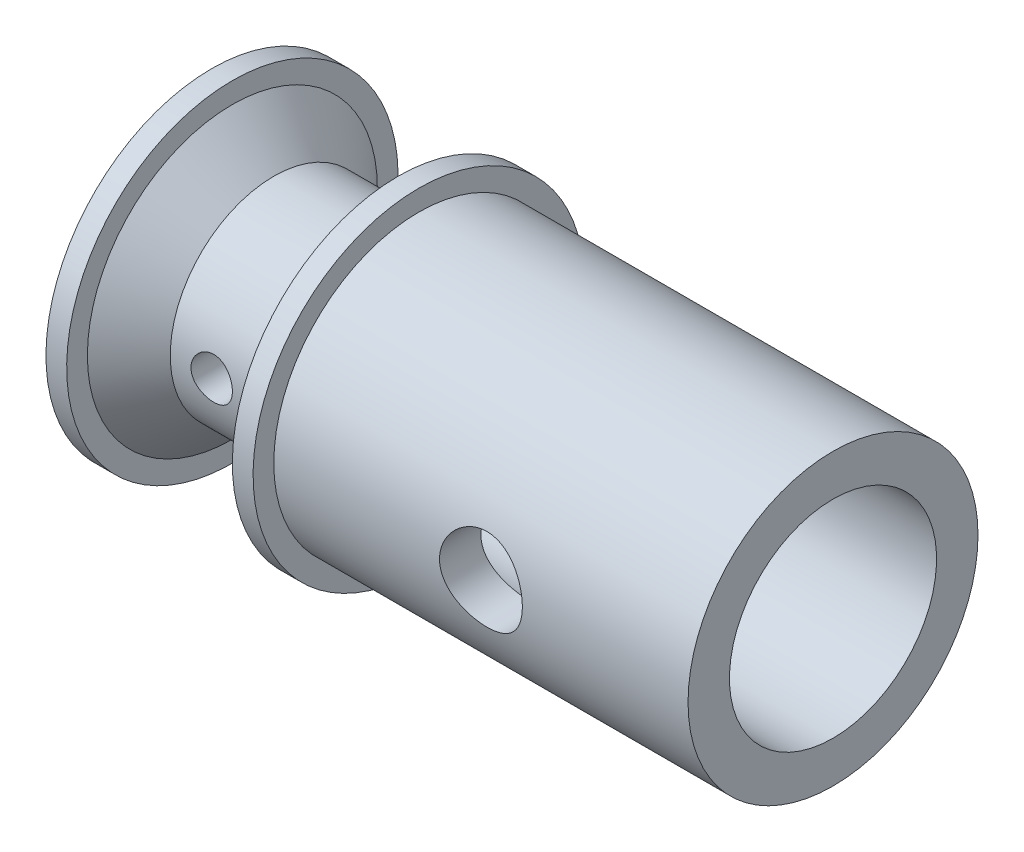
from build123d import *

# Parameters (mm, degrees)
SKETCH3_R               = 0.5
SKETCH3_R_2             = 1
CUT_EXTRUDE1_DEPTH      = 5
CUT_EXTRUDE1_DEPTH_BACK = 5


with BuildPart() as part:
    # Sketch1 → Revolve1 (revolve)
    with BuildSketch(Plane.XY):
        Polygon((0, 0), (0, 2.5), (10, 2.5), (10, 3.5), (0, 3.5), (0, 4), (-0.5, 4), (-0.5, 3.5), (-1.5, 2.5), (-3.5, 2.5), (-4.5, 3.5), (-4.5, 4), (-5, 4), (-5, 0), align=None)
    revolve(axis=Axis((0, 0, 0), (-1, 0, 0)))

    # Sketch3 → Cut-Extrude1 (cut, two sides)
    with BuildSketch(Plane.XY) as cut_extrude1_sk:
        with Locations((-2.5, 0)):
            Circle(SKETCH3_R)
        with Locations((5, 0)):
            Circle(SKETCH3_R_2)
    extrude(amount=CUT_EXTRUDE1_DEPTH, mode=Mode.SUBTRACT)
    extrude(cut_extrude1_sk.sketch, amount=-CUT_EXTRUDE1_DEPTH_BACK, mode=Mode.SUBTRACT)


solid = part.part
